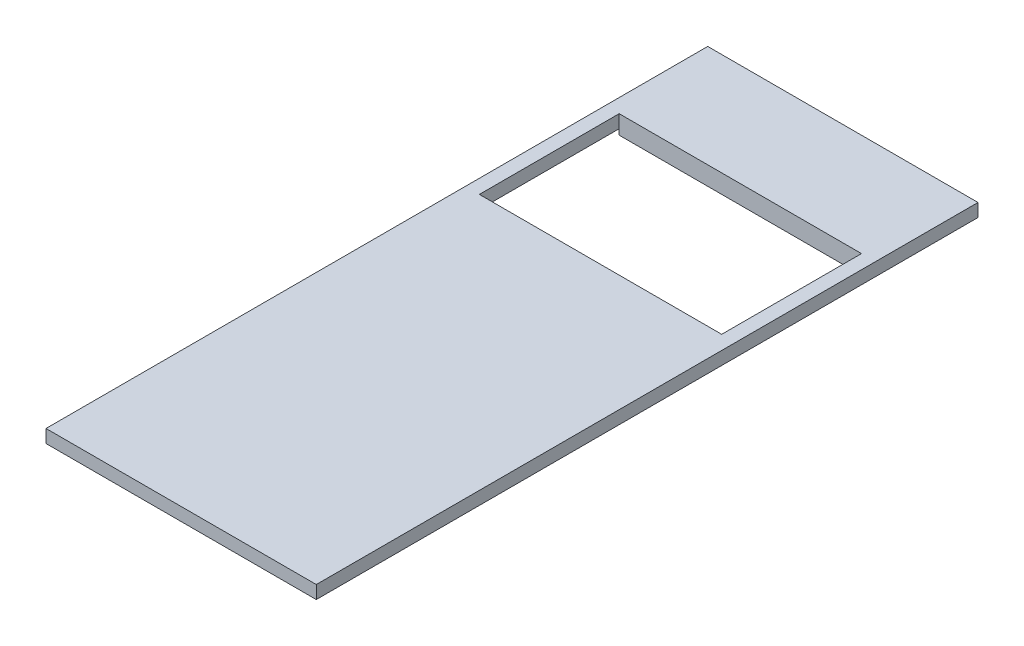
from build123d import *

# Parameters (mm, degrees)
SKETCH1_W           = 26
SKETCH1_H           = 68
BOSS_EXTRUDE1_DEPTH = 0.6
SKETCH2_W           = 29
SKETCH2_H           = 71
BOSS_EXTRUDE2_DEPTH = 1.4
SKETCH3_W           = 26
SKETCH3_H           = 15
CUT_EXTRUDE1_DEPTH  = 15.4


with BuildPart() as part:
    # Sketch1 → Boss-Extrude1 (new body)
    with BuildSketch(Plane(origin=(0, 11.5, 0), x_dir=(1, 0, 0), z_dir=(0, 1, 0))):
        with Locations((14.5, 35.5)):
            Rectangle(SKETCH1_W, SKETCH1_H)
    extrude(amount=-BOSS_EXTRUDE1_DEPTH)

    # Sketch2 → Boss-Extrude2 (add)
    with BuildSketch(Plane(origin=(0, 11.5, 0), x_dir=(1, 0, 0), z_dir=(0, 1, 0))):
        with Locations((14.5, 35.5)):
            Rectangle(SKETCH2_W, SKETCH2_H)
    extrude(amount=BOSS_EXTRUDE2_DEPTH)

    # Sketch3 → Cut-Extrude1 (cut)
    with BuildSketch(Plane.XZ.offset(-10.9)):
        with Locations((14.5, -52.5)):
            Rectangle(SKETCH3_W, SKETCH3_H)
    extrude(amount=-CUT_EXTRUDE1_DEPTH, mode=Mode.SUBTRACT)


solid = part.part
